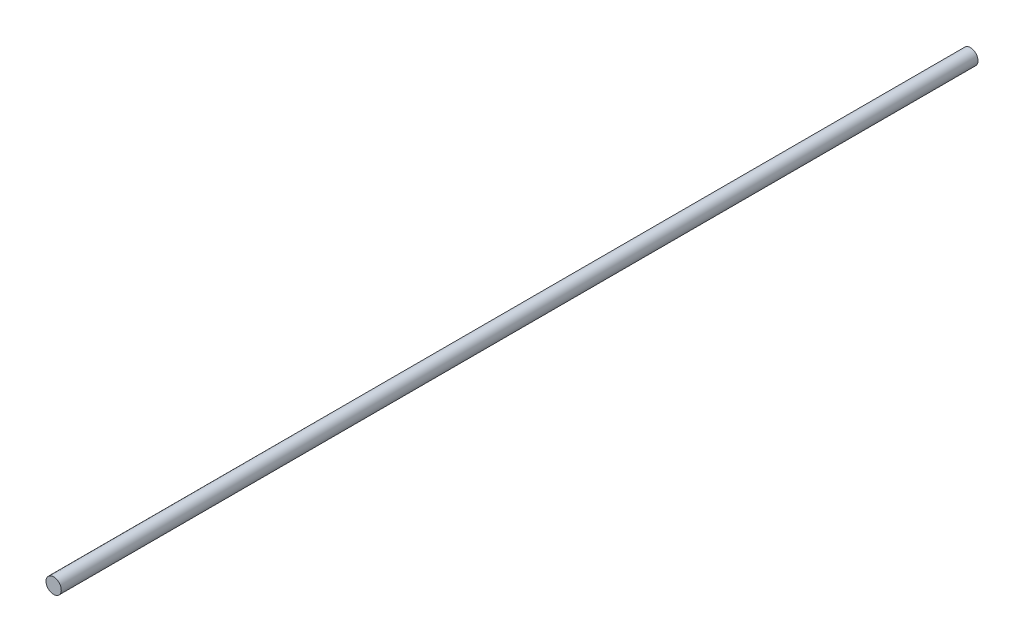
from build123d import *

# Parameters (mm, degrees)
SKETCH1_R           = 5
BOSS_EXTRUDE1_DEPTH = 300


with BuildPart() as part:
    # Sketch1 → Boss-Extrude1 (new body, symmetric)
    with BuildSketch(Plane.XY):
        Circle(SKETCH1_R)
    extrude(amount=BOSS_EXTRUDE1_DEPTH, both=True)


solid = part.part
